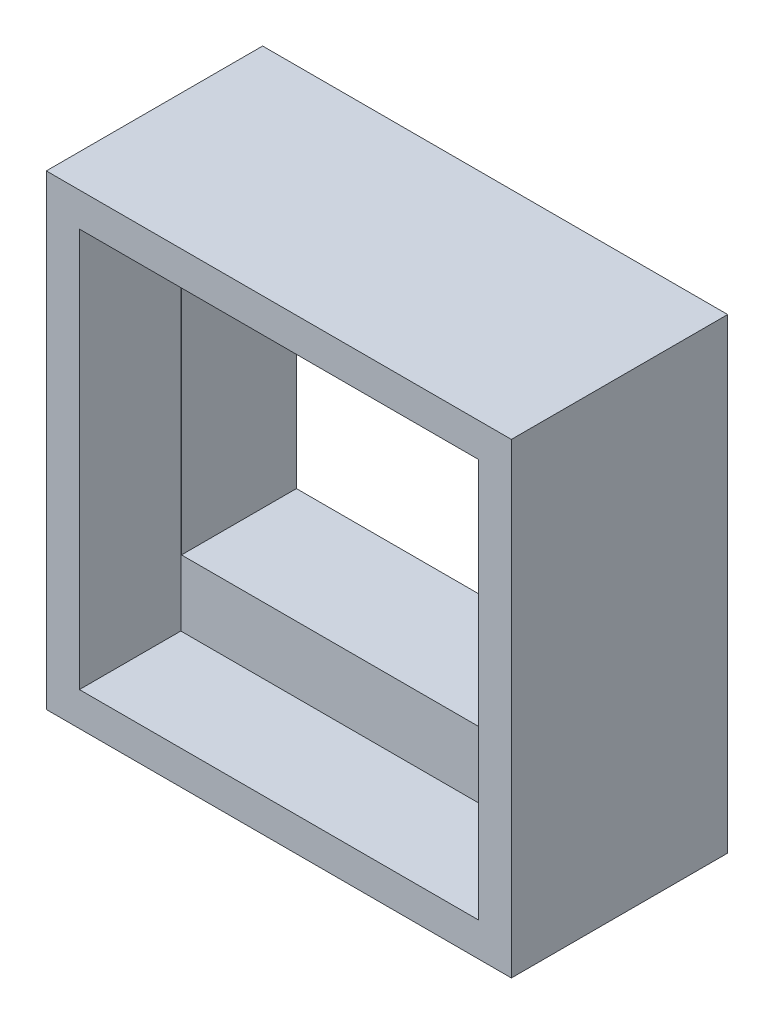
from build123d import *

# Parameters (mm, degrees)
SKETCH_1_W          = 68.8
SKETCH_1_H          = 69
SKETCH_1_W_2        = 58.8
SKETCH_1_H_2        = 39.4
EXTRUDE_1_DEPTH     = 32
SKETCH_5_W          = 59
SKETCH_5_H          = 59
CUT_EXTRUDE_1_DEPTH = 15


with BuildPart() as part:
    # 草圖1 → 填料-伸長1 (new body)
    with BuildSketch(Plane.XY):
        with Locations((1.16067479, -1.986985019)):
            Rectangle(SKETCH_1_W, SKETCH_1_H)
        with Locations((1.16067479, -1.986985019)):
            Rectangle(SKETCH_1_W_2, SKETCH_1_H_2, mode=Mode.SUBTRACT)
    extrude(amount=EXTRUDE_1_DEPTH)

    # 草圖5 → 除料-伸長1 (cut)
    with BuildSketch(Plane.XY.offset(32)):
        with Locations((1.16067479, -1.986985019)):
            Rectangle(SKETCH_5_W, SKETCH_5_H)
    extrude(amount=-CUT_EXTRUDE_1_DEPTH, mode=Mode.SUBTRACT)


solid = part.part
